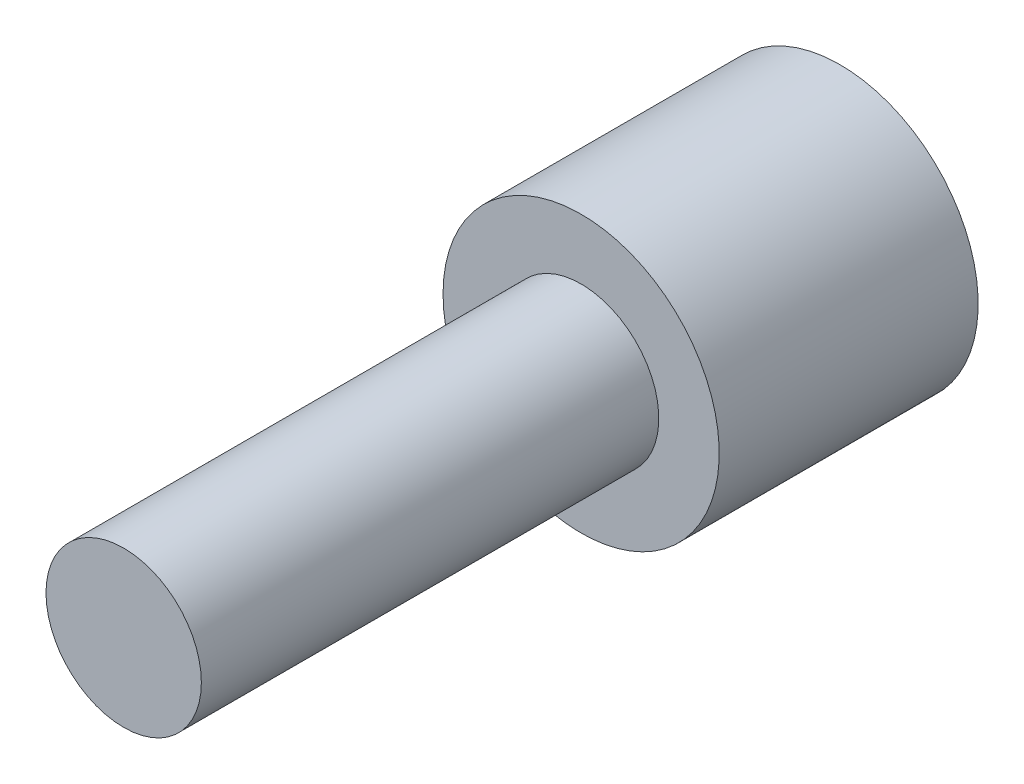
from build123d import *

# Parameters (mm, degrees)
SKETCH2_R           = 1.8
BOSS_EXTRUDE1_DEPTH = 16.6
SKETCH3_R           = 3.2
BOSS_EXTRUDE2_DEPTH = 6


with BuildPart() as part:
    # Sketch2 → Boss-Extrude1 (new body)
    with BuildSketch(Plane.XY):
        Circle(SKETCH2_R)
    extrude(amount=BOSS_EXTRUDE1_DEPTH)

    # Sketch3 → Boss-Extrude2 (add)
    with BuildSketch(Plane(origin=(0, 0, 0), x_dir=(-1, 0, 0), z_dir=(0, 0, -1))):
        Circle(SKETCH3_R)
    extrude(amount=-BOSS_EXTRUDE2_DEPTH)


solid = part.part
